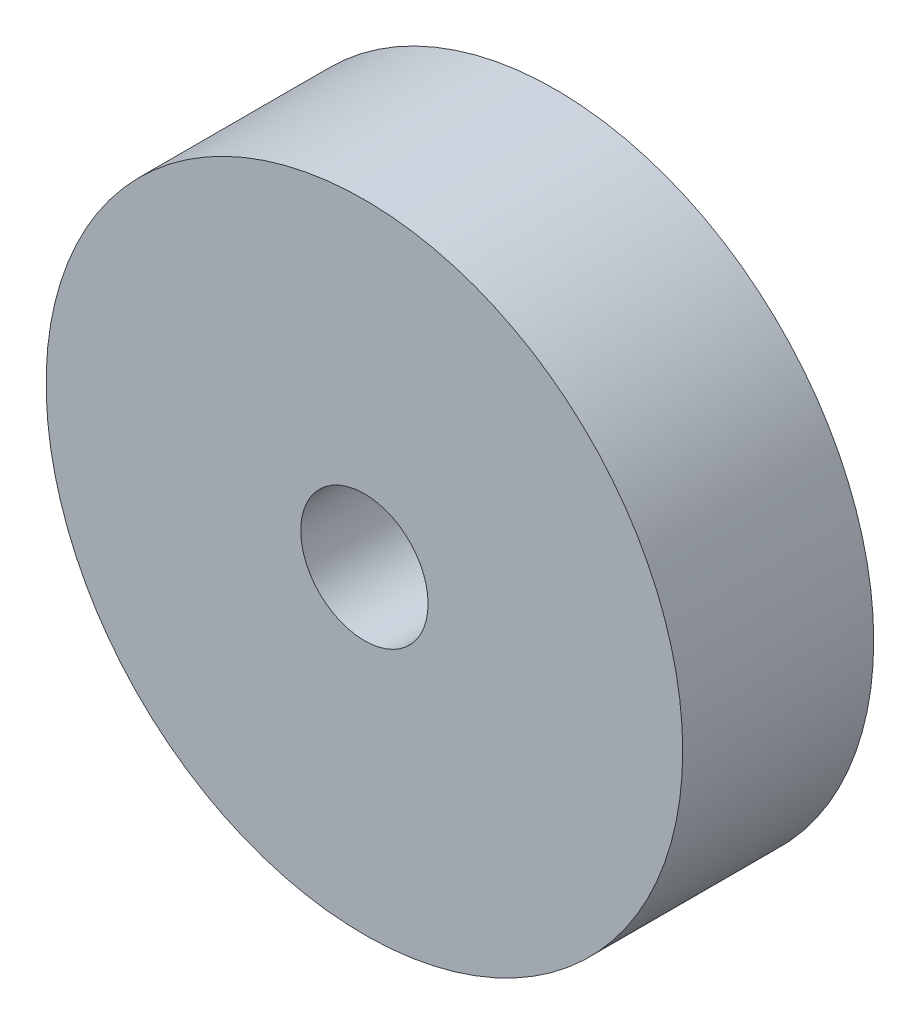
from build123d import *

# Parameters (mm, degrees)
SKETCH1_R           = 20
BOSS_EXTRUDE1_DEPTH = 12
SKETCH2_R           = 4
CUT_EXTRUDE1_DEPTH  = 12


with BuildPart() as part:
    # Sketch1 → Boss-Extrude1 (new body)
    with BuildSketch(Plane.XY):
        Circle(SKETCH1_R)
    extrude(amount=BOSS_EXTRUDE1_DEPTH)

    # Sketch2 → Cut-Extrude1 (cut)
    with BuildSketch(Plane.XY.offset(12)):
        Circle(SKETCH2_R)
    extrude(amount=-CUT_EXTRUDE1_DEPTH, mode=Mode.SUBTRACT)


solid = part.part
